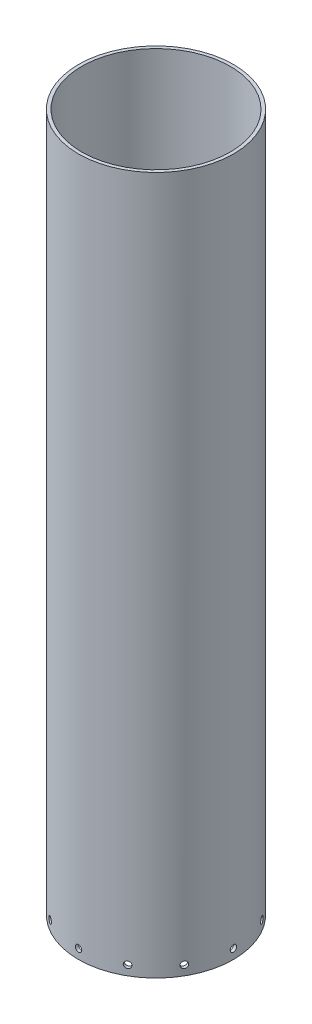
from build123d import *

# Parameters (mm, degrees)
SKETCH2_R           = 76.2
SKETCH2_R_2         = 73.025
BOSS_EXTRUDE1_DEPTH = 685.8
SKETCH3_R           = 3.175
CUT_EXTRUDE1_DEPTH  = 77.2
CIRPATTERN1_COUNT   = 12


with BuildPart() as part:
    # Sketch2 → Boss-Extrude1 (new body)
    with BuildSketch(Plane(origin=(0, 0, 0), x_dir=(1, 0, 0), z_dir=(0, 1, 0))):
        Circle(SKETCH2_R)
        Circle(SKETCH2_R_2, mode=Mode.SUBTRACT)
    extrude(amount=BOSS_EXTRUDE1_DEPTH)

    # Sketch3 → Cut-Extrude1 (cut, through all)
    with BuildSketch(Plane.XY):
        with Locations((0, 9.525)):
            Circle(SKETCH3_R)
    cut_extrude1 = extrude(amount=-CUT_EXTRUDE1_DEPTH, mode=Mode.SUBTRACT)

    # CirPattern1: Cut-Extrude1 ×12 about axis
    cirpattern1_axis = Axis((0, 0, 0), (0, 1, 0))
    for i in range(1, CIRPATTERN1_COUNT):
        add(cut_extrude1.rotate(cirpattern1_axis, i * 360 / CIRPATTERN1_COUNT), mode=Mode.SUBTRACT)


solid = part.part
